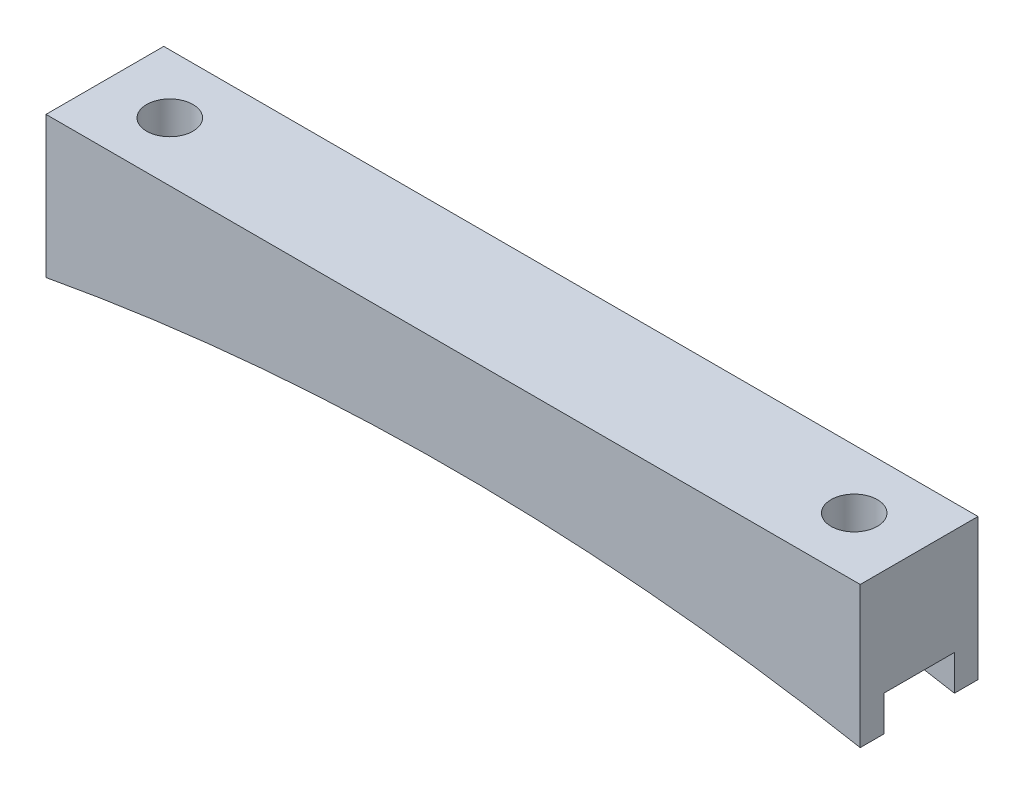
from build123d import *

# Parameters (mm, degrees)
BOSS_EXTRUDE1_DEPTH = 12.7
SKETCH2_R           = 2.5
CUT_EXTRUDE1_DEPTH  = 16.24
SKETCH3_W           = 7.62
SKETCH3_H           = 3.81
CUT_EXTRUDE2_DEPTH  = 88.8100001


with BuildPart() as part:
    # Sketch1 → Boss-Extrude1 (new body)
    with BuildSketch(Plane.XY):
        with BuildLine():
            Line((-43.905, 0), (43.905, 0))
            Line((43.905, 0), (43.905, -15.24))
            ThreePointArc((43.905, -15.24), (0, -11.212082165), (-43.905, -15.24))
            Line((-43.905, -15.24), (-43.905, 0))
        make_face()
    extrude(amount=BOSS_EXTRUDE1_DEPTH)

    # Sketch2 → Cut-Extrude1 (cut, through all)
    with BuildSketch(Plane(origin=(0, 0, 0), x_dir=(1, 0, 0), z_dir=(0, 1, 0))):
        with Locations((-36.905, -6.35)):
            Circle(SKETCH2_R)
        with Locations((36.905, -6.35)):
            Circle(SKETCH2_R)
    extrude(amount=-CUT_EXTRUDE1_DEPTH, mode=Mode.SUBTRACT)

    # Sketch3 → Cut-Extrude2 (cut, through all)
    with BuildSketch(Plane(origin=(43.905, 0, 0), x_dir=(0, 0, -1), z_dir=(1, 0, 0))):
        with Locations((-6.35, -13.335)):
            Rectangle(SKETCH3_W, SKETCH3_H)
    extrude(amount=-CUT_EXTRUDE2_DEPTH, mode=Mode.SUBTRACT)


solid = part.part
